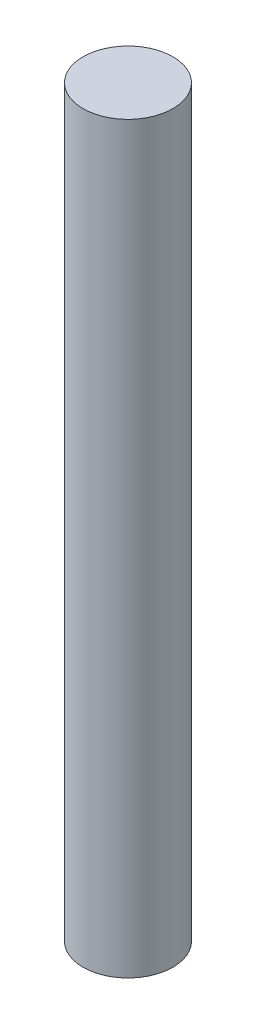
from build123d import *

# Parameters (mm, degrees)
SKETCH1_R           = 1.45
BOSS_EXTRUDE1_DEPTH = 24


with BuildPart() as part:
    # Sketch1 → Boss-Extrude1 (new body)
    with BuildSketch(Plane(origin=(0, 0, 0), x_dir=(1, 0, 0), z_dir=(0, 1, 0))):
        Circle(SKETCH1_R)
    extrude(amount=BOSS_EXTRUDE1_DEPTH)


solid = part.part
